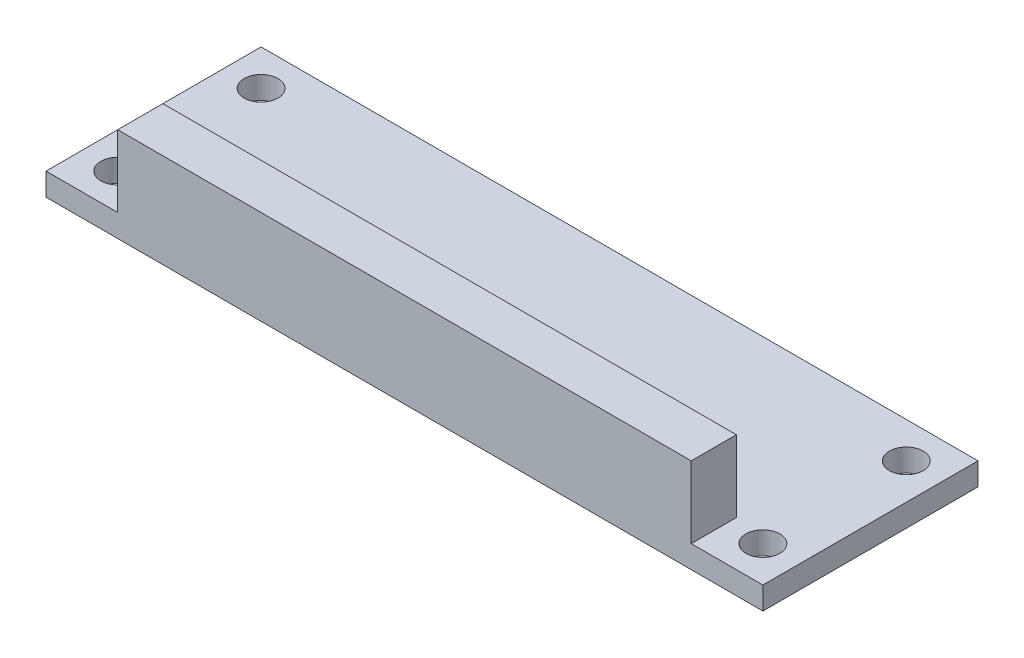
from build123d import *

# Parameters (mm, degrees)
SKETCH4_W           = 63.5
SKETCH4_H           = 19.05
SKETCH4_R           = 1.5
BOSS_EXTRUDE2_DEPTH = 2
SKETCH6_W           = 50.8
SKETCH6_H           = 4
BOSS_EXTRUDE3_DEPTH = 6.35


with BuildPart() as part:
    # Sketch4 → Boss-Extrude2 (new body)
    with BuildSketch(Plane(origin=(0, 0, 0), x_dir=(1, 0, 0), z_dir=(0, 1, 0))):
        Rectangle(SKETCH4_W, SKETCH4_H)
        with Locations((28.575, 6.35)):
            Circle(SKETCH4_R, mode=Mode.SUBTRACT)
        with Locations((28.575, -6.35)):
            Circle(SKETCH4_R, mode=Mode.SUBTRACT)
        with Locations((-28.575, -6.35)):
            Circle(SKETCH4_R, mode=Mode.SUBTRACT)
        with Locations((-28.575, 6.35)):
            Circle(SKETCH4_R, mode=Mode.SUBTRACT)
    extrude(amount=BOSS_EXTRUDE2_DEPTH)

    # Sketch6 → Boss-Extrude3 (add)
    with BuildSketch(Plane(origin=(0, 2, 0), x_dir=(1, 0, 0), z_dir=(0, 1, 0))):
        with Locations((0, -7.525)):
            Rectangle(SKETCH6_W, SKETCH6_H)
    extrude(amount=BOSS_EXTRUDE3_DEPTH)


solid = part.part
